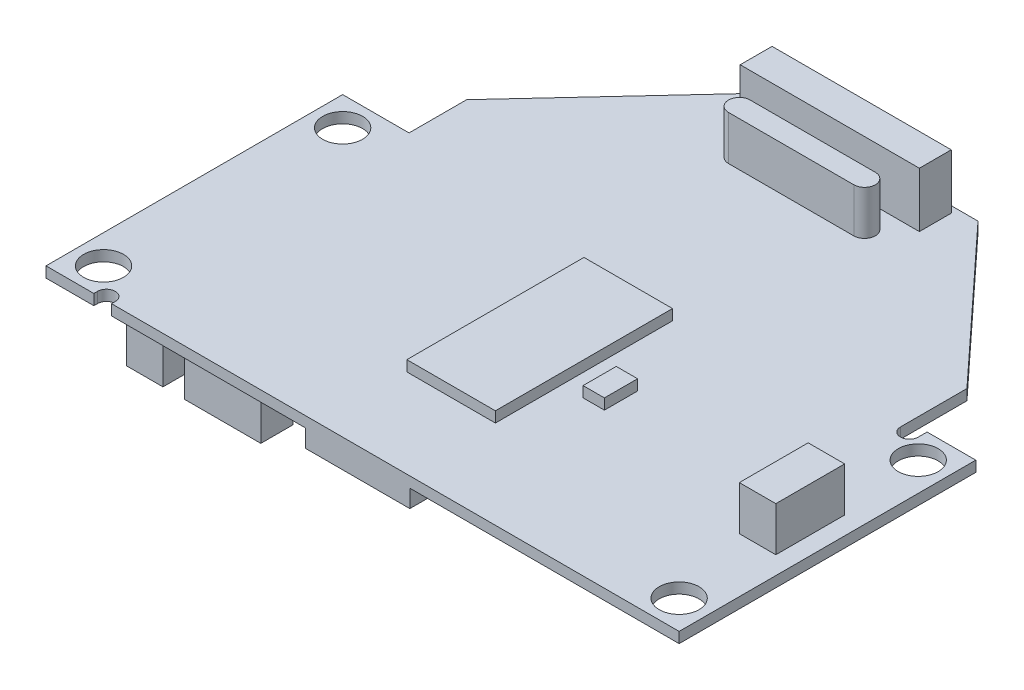
from build123d import *

# Parameters (mm, degrees)
ESQUISSE1_R      = 2.25
EXTRUSION1_DEPTH = 1.2
EXTRUSION2_DEPTH = 1.2
ESQUISSE3_W      = 10
ESQUISSE3_H      = 20
ESQUISSE3_W_2    = 2.40813479
ESQUISSE3_H_2    = 3.745987449
EXTRUSION3_DEPTH = 1.2
ESQUISSE4_W      = 4.120783465
ESQUISSE4_H      = 7.773296082
EXTRUSION4_DEPTH = 5
ESQUISSE5_W      = 20.236263024
ESQUISSE5_H      = 3.599719865
EXTRUSION5_DEPTH = 6.2
ESQUISSE6_W      = 11.800425377
ESQUISSE6_H      = 8.897146118
ESQUISSE6_W_2    = 12.081387885
ESQUISSE6_H_2    = 11.894079546
ESQUISSE6_W_3    = 5.900212688
ESQUISSE6_H_3    = 6.087521028
ESQUISSE6_W_4    = 7.866950251
ESQUISSE6_H_4    = 6.368483537
ESQUISSE6_W_5    = 3.090587599
ESQUISSE6_H_5    = 4.963670992
EXTRUSION6_DEPTH = 1.2
ESQUISSE7_R      = 3.251027485
ESQUISSE7_R_2    = 2.665444396
ESQUISSE7_R_3    = 3.383236625
EXTRUSION7_DEPTH = 4
ESQUISSE8_W      = 11.800425376
ESQUISSE8_H      = 4.14991589
EXTRUSION8_DEPTH = 2
ESQUISSE9_W      = 4.120783464
ESQUISSE9_H      = 6.087521028
ESQUISSE9_W_2    = 8.616183609
ESQUISSE9_H_2    = 3.652512617
EXTRUSION9_DEPTH = 5


with BuildPart() as part:
    # Esquisse1 → Extrusion1 (new body)
    with BuildSketch(Plane(origin=(0, 0, 0), x_dir=(1, 0, 0), z_dir=(0, 1, 0))):
        Polygon((-35.75, 0), (35.75, 0), (35.75, 33.5), (28.25, 33.5), (28.25, 40), (12.5, 57), (-12.5, 57), (-28.25, 40), (-28.25, 33.5), (-35.75, 33.5), align=None)
        with Locations(Location((32.5, 30.25, 0), (0, 0, 270))):  # turned: the seam where the file's is
            Circle(ESQUISSE1_R, mode=Mode.SUBTRACT)
        with Locations(Location((32.5, 3.25, 0), (0, 0, 270))):  # turned: the seam where the file's is
            Circle(ESQUISSE1_R, mode=Mode.SUBTRACT)
        with Locations(Location((-32.5, 3.25, 0), (0, 0, 90))):  # turned: the seam where the file's is
            Circle(ESQUISSE1_R, mode=Mode.SUBTRACT)
        with Locations(Location((-32.5, 30.25, 0), (0, 0, 90))):  # turned: the seam where the file's is
            Circle(ESQUISSE1_R, mode=Mode.SUBTRACT)
    extrude(amount=EXTRUSION1_DEPTH)

    # Esquisse2 → Extrusion2 (cut)
    with BuildSketch(Plane(origin=(0, 1.2, 0), x_dir=(1, 0, 0), z_dir=(0, 1, 0))):
        with BuildLine():
            Line((28.25, 33.5), (28.25, 32.5))
            ThreePointArc((28.25, 32.5), (29.25, 31.5), (30.25, 32.5))
            Line((30.25, 32.5), (30.25, 33.5))
            Line((30.25, 33.5), (28.25, 33.5))
        make_face()
        with BuildLine():
            Line((-30.347117409, 0.422704879), (-30.347117409, 0))
            Line((-30.347117409, 0), (-28.347117409, 0))
            Line((-28.347117409, 0), (-28.347117409, 0.422704879))
            ThreePointArc((-28.347117409, 0.422704879), (-29.347117409, 1.422704879), (-30.347117409, 0.422704879))
        make_face()
    extrude(amount=-EXTRUSION2_DEPTH, mode=Mode.SUBTRACT)

    # Esquisse3 → Extrusion3 (add)
    with BuildSketch(Plane(origin=(0, 1.2, 0), x_dir=(1, 0, 0), z_dir=(0, 1, 0))):
        with Locations((0, 20)):
            Rectangle(ESQUISSE3_W, ESQUISSE3_H)
        with Locations((8.690081326, 19.288860946)):
            Rectangle(ESQUISSE3_W_2, ESQUISSE3_H_2)
    extrude(amount=EXTRUSION3_DEPTH)

    # Esquisse4 → Extrusion4 (add)
    with BuildSketch(Plane(origin=(0, 1.2, 0), x_dir=(1, 0, 0), z_dir=(0, 1, 0))):
        with Locations((31.655109344, 16.840055878)):
            Rectangle(ESQUISSE4_W, ESQUISSE4_H)
        with BuildLine():
            Line((-7.211371063, 50.977000717), (6.930408555, 50.977000717))
            ThreePointArc((6.930408555, 50.977000717), (8.14791276, 49.759496512), (6.930408555, 48.541992306))
            Line((6.930408555, 48.541992306), (-7.211371063, 48.541992306))
            ThreePointArc((-7.211371063, 48.541992306), (-8.428875269, 49.759496512), (-7.211371063, 50.977000717))
        make_face()
    extrude(amount=EXTRUSION4_DEPTH)

    # Esquisse5 → Extrusion5 (add)
    with BuildSketch(Plane(origin=(0, 1.2, 0), x_dir=(1, 0, 0), z_dir=(0, 1, 0))):
        with Locations((0.097289726, 54.463865055)):
            Rectangle(ESQUISSE5_W, ESQUISSE5_H)
    extrude(amount=EXTRUSION5_DEPTH)

    # Esquisse6 → Extrusion6 (add)
    with BuildSketch(Plane.XZ):
        with Locations((17.326021387, -35.008964791)):
            Rectangle(ESQUISSE6_W, ESQUISSE6_H)
        with Locations((21.587286106, -21.7100727)):
            Rectangle(ESQUISSE6_W_2, ESQUISSE6_H_2)
        with Locations((-16.061690096, -23.395847754)):
            Rectangle(ESQUISSE6_W_3, ESQUISSE6_H_3)
        with Locations((-4.776362653, -40.675042056)):
            Rectangle(ESQUISSE6_W_4, ESQUISSE6_H_4)
        with Locations((-22.430173633, -34.259731434)):
            Rectangle(ESQUISSE6_W_5, ESQUISSE6_H_5)
    extrude(amount=EXTRUSION6_DEPTH)

    # Esquisse7 → Extrusion7 (add)
    with BuildSketch(Plane.XZ):
        with Locations(Location((-13.5798546, -38.989267001, 0), (0, 0, 90))):  # turned: the seam where the file's is
            Circle(ESQUISSE7_R)
        with Locations(Location((-31.5, -10, 0), (0, 0, 90))):  # turned: the seam where the file's is
            Circle(ESQUISSE7_R_2)
        with Locations(Location((0, -14.199376853, 0), (0, 0, 90))):  # turned: the seam where the file's is
            Circle(ESQUISSE7_R_3)
    extrude(amount=EXTRUSION7_DEPTH)

    # Esquisse8 → Extrusion8 (add)
    with BuildSketch(Plane.XZ):
        with Locations((-0.561925018, -2.074957945)):
            Rectangle(ESQUISSE8_W, ESQUISSE8_H)
    extrude(amount=EXTRUSION8_DEPTH)

    # Esquisse9 → Extrusion9 (add)
    with BuildSketch(Plane.XZ):
        with Locations((-25.567588316, -4.009434635)):
            Rectangle(ESQUISSE9_W, ESQUISSE9_H)
        with Locations((-16.764096368, -2.79193043)):
            Rectangle(ESQUISSE9_W_2, ESQUISSE9_H_2)
    extrude(amount=EXTRUSION9_DEPTH)


solid = part.part
